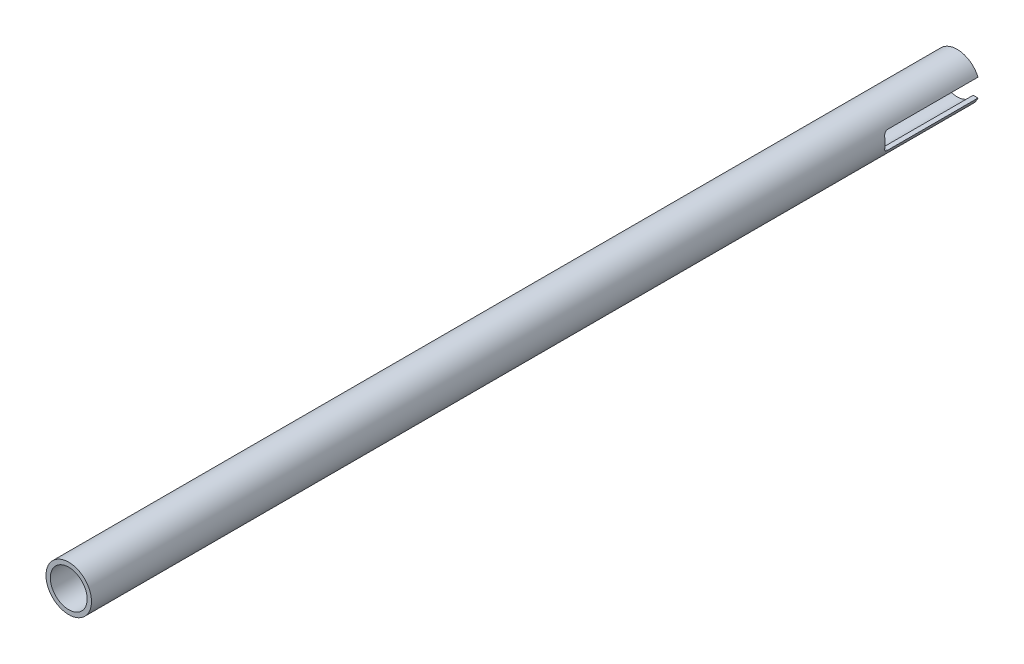
from build123d import *

# Parameters (mm, degrees)
SKETCH1_R               = 8.001
SKETCH1_R_2             = 6.477
BOSS_EXTRUDE1_DEPTH     = 312.42
CUT_EXTRUDE2_DEPTH      = 9.001
CUT_EXTRUDE2_DEPTH_BACK = 9.001


with BuildPart() as part:
    # Sketch1 → Boss-Extrude1 (new body)
    with BuildSketch(Plane.XY):
        Circle(SKETCH1_R)
        Circle(SKETCH1_R_2, mode=Mode.SUBTRACT)
    extrude(amount=BOSS_EXTRUDE1_DEPTH)

    # Sketch2 → Cut-Extrude2 (cut, two sides)
    with BuildSketch(Plane(origin=(0, 0, 0), x_dir=(0, 0, -1), z_dir=(1, 0, 0))) as cut_extrude2_sk:
        with BuildLine():
            Line((635.239664052, 3.175), (0, 3.175))
            Line((0, 3.175), (-31.75, 3.175))
            ThreePointArc((-31.75, 3.175), (-32.827630735, 2.728630735), (-33.274, 1.651))
            Line((-33.274, 1.651), (-33.274, -1.651))
            ThreePointArc((-33.274, -1.651), (-32.827630735, -2.728630735), (-31.75, -3.175))
            Line((-31.75, -3.175), (0, -3.175))
            Line((0, -3.175), (635.239664052, -3.175))
            Line((635.239664052, -3.175), (1905.718992156, -3.175))
            Line((1905.718992156, -3.175), (1905.718992156, 3.175))
            Line((1905.718992156, 3.175), (635.239664052, 3.175))
        make_face()
    extrude(amount=CUT_EXTRUDE2_DEPTH, mode=Mode.SUBTRACT)
    extrude(cut_extrude2_sk.sketch, amount=-CUT_EXTRUDE2_DEPTH_BACK, mode=Mode.SUBTRACT)


solid = part.part
